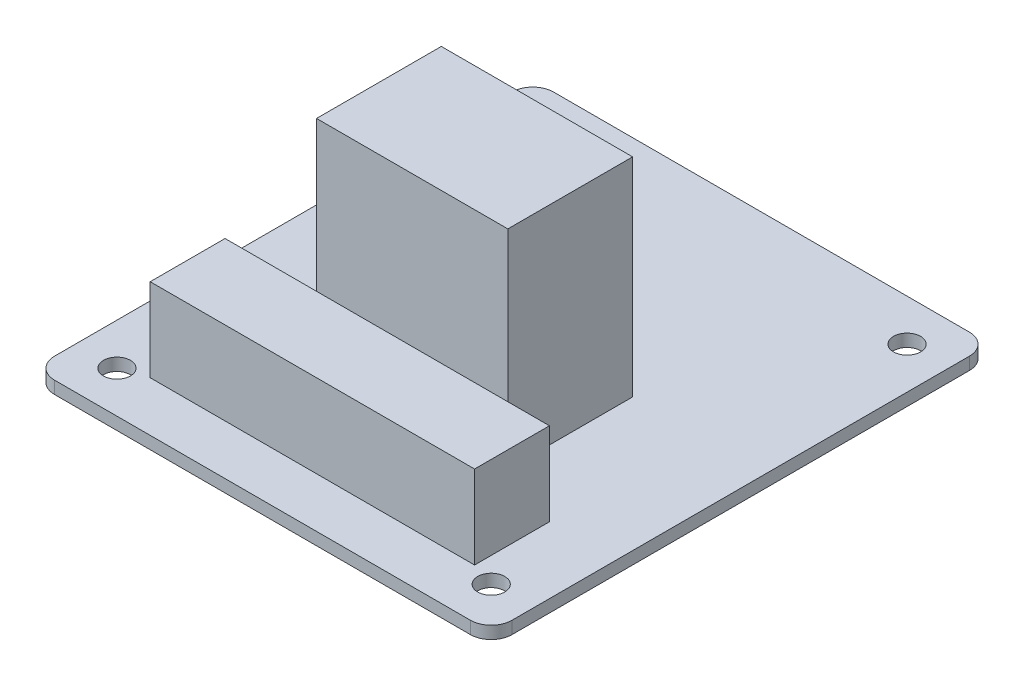
from build123d import *

# Parameters (mm, degrees)
SKETCH1_R           = 1.625
SKETCH1_W           = 23
SKETCH1_H           = 15
SKETCH1_W_2         = 39
SKETCH1_H_2         = 9
BOSS_EXTRUDE1_DEPTH = 1.5
BOSS_EXTRUDE2_START = 1.5
SKETCH1_4_W         = 39
SKETCH1_4_H         = 9
BOSS_EXTRUDE2_DEPTH = 10
BOSS_EXTRUDE3_START = 1.5
SKETCH1_5_W         = 23
SKETCH1_5_H         = 15
BOSS_EXTRUDE3_DEPTH = 25


with BuildPart() as part:
    # Sketch1 → Boss-Extrude1 (new body)
    with BuildSketch(Plane(origin=(0, 0, 0), x_dir=(1, 0, 0), z_dir=(0, 1, 0))):
        with BuildLine():
            ThreePointArc((0, 57.5), (0.732233047, 59.267766953), (2.5, 60))
            Line((2.5, 60), (52.5, 60))
            ThreePointArc((52.5, 60), (54.267766953, 59.267766953), (55, 57.5))
            Line((55, 57.5), (55, 2.5))
            ThreePointArc((55, 2.5), (54.267766953, 0.732233047), (52.5, 0))
            Line((52.5, 0), (2.5, 0))
            ThreePointArc((2.5, 0), (0.732233047, 0.732233047), (0, 2.5))
            Line((0, 2.5), (0, 57.5))
        make_face()
        with Locations((50, 5)):
            Circle(SKETCH1_R, mode=Mode.SUBTRACT)
        with Locations((5, 5)):
            Circle(SKETCH1_R, mode=Mode.SUBTRACT)
        with Locations((50, 55)):
            Circle(SKETCH1_R, mode=Mode.SUBTRACT)
        with Locations((5, 55)):
            Circle(SKETCH1_R, mode=Mode.SUBTRACT)
        with Locations((27.5, 25.5)):
            Rectangle(SKETCH1_W, SKETCH1_H, mode=Mode.SUBTRACT)
        with Locations((27.5, 10.5)):
            Rectangle(SKETCH1_W_2, SKETCH1_H_2, mode=Mode.SUBTRACT)
        with Locations((27.5, 25.5)):
            Rectangle(SKETCH1_W, SKETCH1_H)
        with Locations((27.5, 10.5)):
            Rectangle(SKETCH1_W_2, SKETCH1_H_2)
    extrude(amount=BOSS_EXTRUDE1_DEPTH)


with BuildPart() as body_2:
    # Sketch1_4 → Boss-Extrude2 (new body)
    with BuildSketch(Plane(origin=(0, 0, 0), x_dir=(1, 0, 0), z_dir=(0, 1, 0)).offset(BOSS_EXTRUDE2_START)):
        with Locations((27.5, 10.5)):
            Rectangle(SKETCH1_4_W, SKETCH1_4_H)
    extrude(amount=BOSS_EXTRUDE2_DEPTH)


with BuildPart() as body_3:
    # Sketch1_5 → Boss-Extrude3 (new body)
    with BuildSketch(Plane(origin=(0, 0, 0), x_dir=(1, 0, 0), z_dir=(0, 1, 0)).offset(BOSS_EXTRUDE3_START)):
        with Locations((27.5, 25.5)):
            Rectangle(SKETCH1_5_W, SKETCH1_5_H)
    extrude(amount=BOSS_EXTRUDE3_DEPTH)


solid = Compound([part.part, body_2.part, body_3.part])
